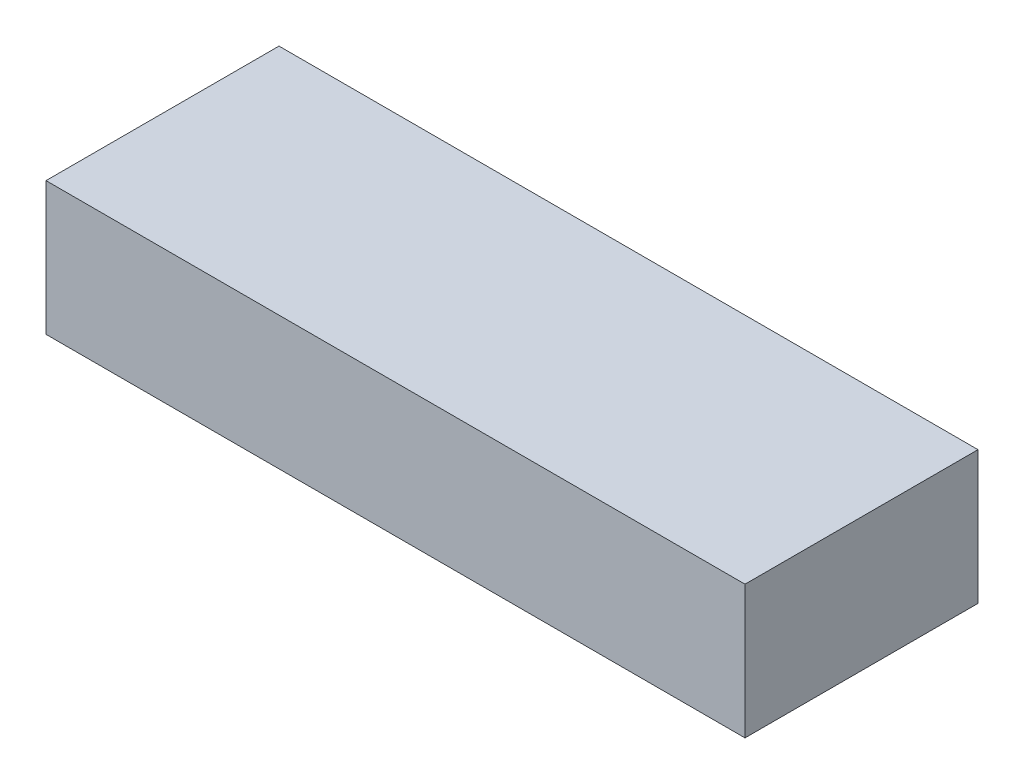
from build123d import *

# Parameters (mm, degrees)
SKETCH1_W           = 105
SKETCH1_H           = 35
BOSS_EXTRUDE1_DEPTH = 20


with BuildPart() as part:
    # Sketch1 → Boss-Extrude1 (new body)
    with BuildSketch(Plane(origin=(0, 0, 0), x_dir=(1, 0, 0), z_dir=(0, 1, 0))):
        with Locations((5.357142857, -1)):
            Rectangle(SKETCH1_W, SKETCH1_H)
    extrude(amount=BOSS_EXTRUDE1_DEPTH)


solid = part.part
